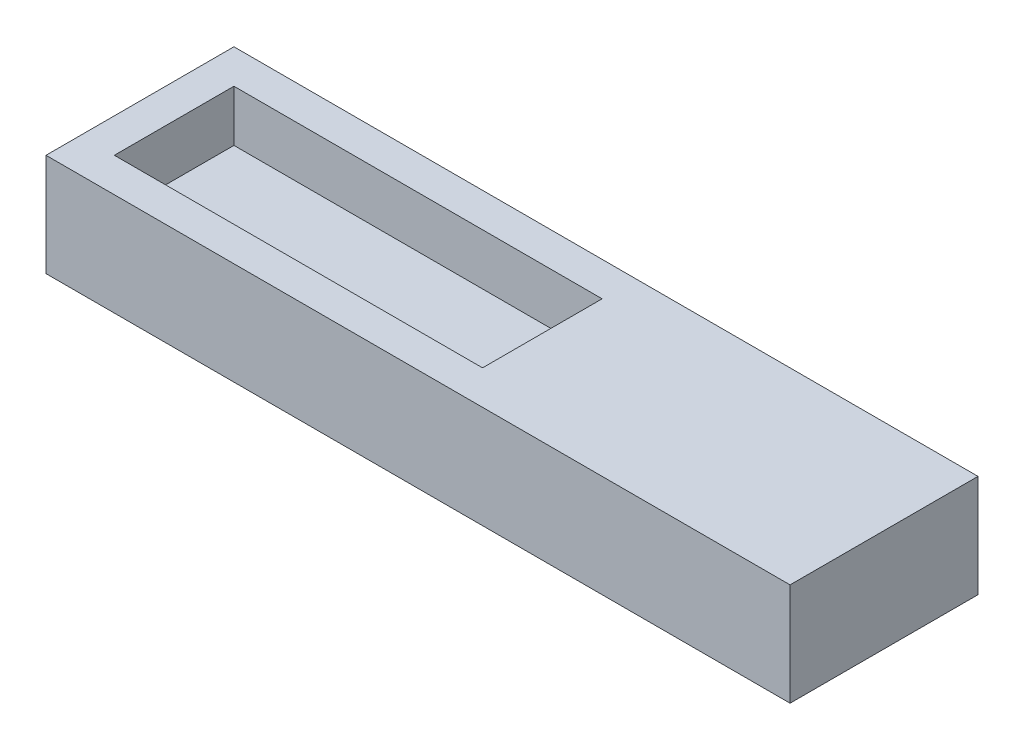
from build123d import *

# Parameters (mm, degrees)
SKETCH1_W           = 43.55
SKETCH1_H           = 11
SKETCH1_W_2         = 21.55
SKETCH1_H_2         = 7
BOSS_EXTRUDE1_DEPTH = 3
SKETCH1_2_W         = 43.55
SKETCH1_2_H         = 11
BOSS_EXTRUDE2_DEPTH = 3


with BuildPart() as part:
    # Sketch1 → Boss-Extrude1 (new body)
    with BuildSketch(Plane(origin=(0, 0, 0), x_dir=(1, 0, 0), z_dir=(0, 1, 0))):
        with Locations((21.775, -5.5)):
            Rectangle(SKETCH1_W, SKETCH1_H)
        with Locations((12.775, -5.5)):
            Rectangle(SKETCH1_W_2, SKETCH1_H_2, mode=Mode.SUBTRACT)
    extrude(amount=BOSS_EXTRUDE1_DEPTH)

    # Sketch1_2 → Boss-Extrude2 (add)
    with BuildSketch(Plane(origin=(0, 0, 0), x_dir=(1, 0, 0), z_dir=(0, 1, 0))):
        with Locations((21.775, -5.5)):
            Rectangle(SKETCH1_2_W, SKETCH1_2_H)
    extrude(amount=-BOSS_EXTRUDE2_DEPTH)


solid = part.part
